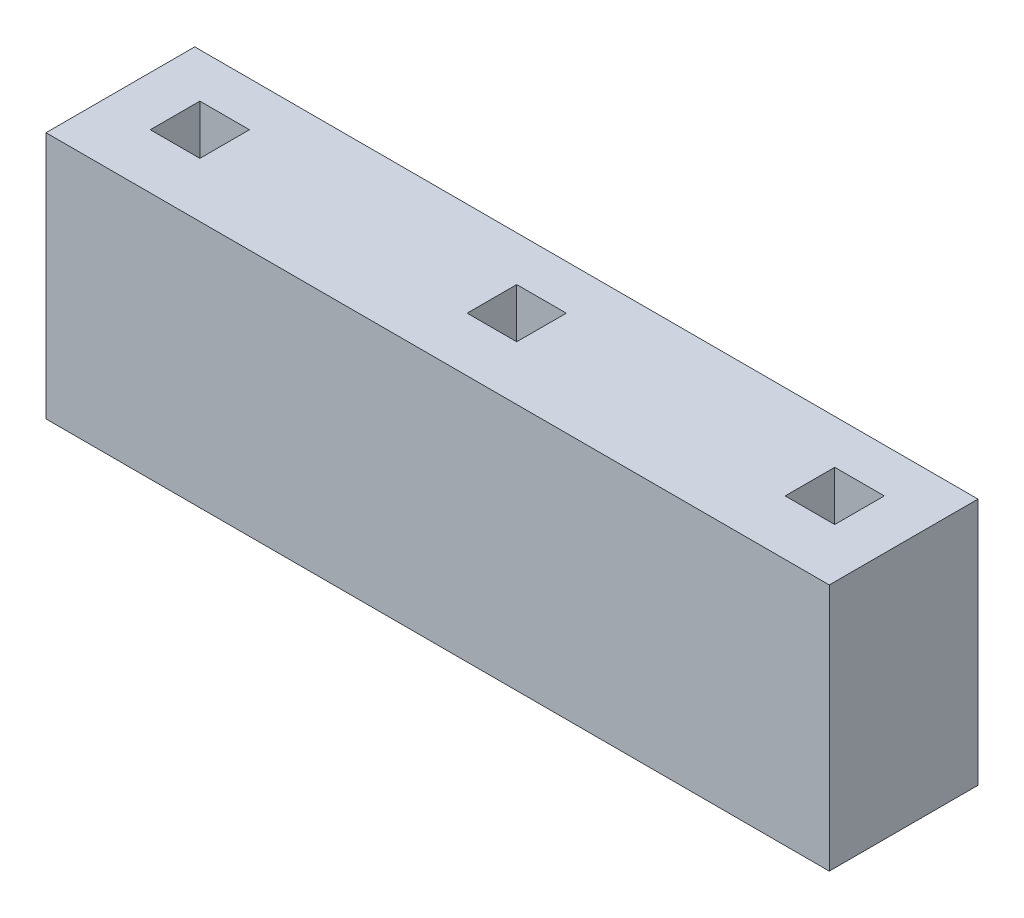
from build123d import *

# Parameters (mm, degrees)
SKETCH1_W           = 7.9
SKETCH1_H           = 1.5
SKETCH1_W_2         = 0.5
SKETCH1_H_2         = 0.5
BOSS_EXTRUDE1_DEPTH = 2.5


with BuildPart() as part:
    # Sketch1 → Boss-Extrude1 (new body)
    with BuildSketch(Plane(origin=(0, 0, 0), x_dir=(1, 0, 0), z_dir=(0, 1, 0))):
        with Locations((2.505127678, 0.264314746)):
            Rectangle(SKETCH1_W, SKETCH1_H)
        with Locations((-0.694872322, 0.316232633)):
            Rectangle(SKETCH1_W_2, SKETCH1_H_2, mode=Mode.SUBTRACT)
        with Locations((5.705127678, 0.319368521)):
            Rectangle(SKETCH1_W_2, SKETCH1_H_2, mode=Mode.SUBTRACT)
        with Locations((2.505127678, 0.311937798)):
            Rectangle(SKETCH1_W_2, SKETCH1_H_2, mode=Mode.SUBTRACT)
    extrude(amount=BOSS_EXTRUDE1_DEPTH)


solid = part.part
